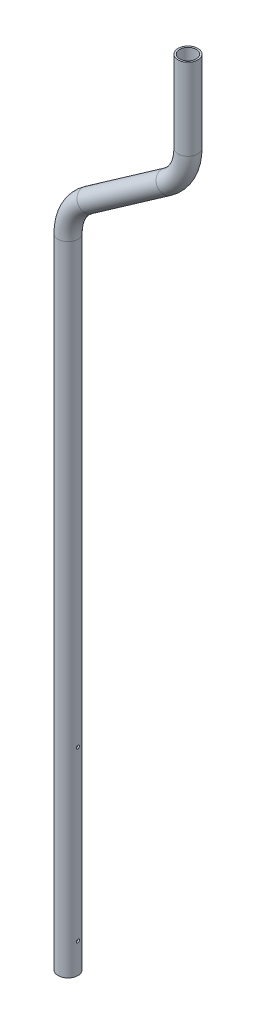
from build123d import *

# Parameters (mm, degrees)
SKETCH3_R               = 21.082
SKETCH3_R_2             = 17.526
SKETCH5_R               = 3.3734375
CUT_EXTRUDE1_DEPTH      = 276.0820001
CUT_EXTRUDE1_DEPTH_BACK = 22.0820001


with BuildPart() as part:
    # Sweep1: sweep along a path in Sketch2
    with BuildLine(Plane.XY) as sweep1_path:
        Line((0, 0), (0, 1350.407672959))
        ThreePointArc((0, 1350.407672959), (11.479699349, 1397.321332063), (43.324634067, 1433.633520658))
        Line((43.324634067, 1433.633520658), (210.675365933, 1550.813764636))
        ThreePointArc((210.675365933, 1550.813764636), (242.520300651, 1587.125953231), (254, 1634.039612336))
        Line((254, 1634.039612336), (254, 1806.575))
    # Sketch3 → Sweep1 (sweep)
    with BuildSketch(Plane(origin=(0, 1806.575, 0), x_dir=(1, 0, 0), z_dir=(0, 1, 0))):
        with Locations((254, 0)):
            Circle(SKETCH3_R)
        with Locations((254, 0)):
            Circle(SKETCH3_R_2, mode=Mode.SUBTRACT)
    sweep(path=sweep1_path.line)

    # Sketch5 → Cut-Extrude1 (cut, two sides)
    with BuildSketch(Plane(origin=(0, 0, 0), x_dir=(0, 0, -1), z_dir=(1, 0, 0))) as cut_extrude1_sk:
        with Locations((0, 63.5)):
            Circle(SKETCH5_R)
        with Locations((0, 419.1)):
            Circle(SKETCH5_R)
    extrude(amount=CUT_EXTRUDE1_DEPTH, mode=Mode.SUBTRACT)
    extrude(cut_extrude1_sk.sketch, amount=-CUT_EXTRUDE1_DEPTH_BACK, mode=Mode.SUBTRACT)


solid = part.part
